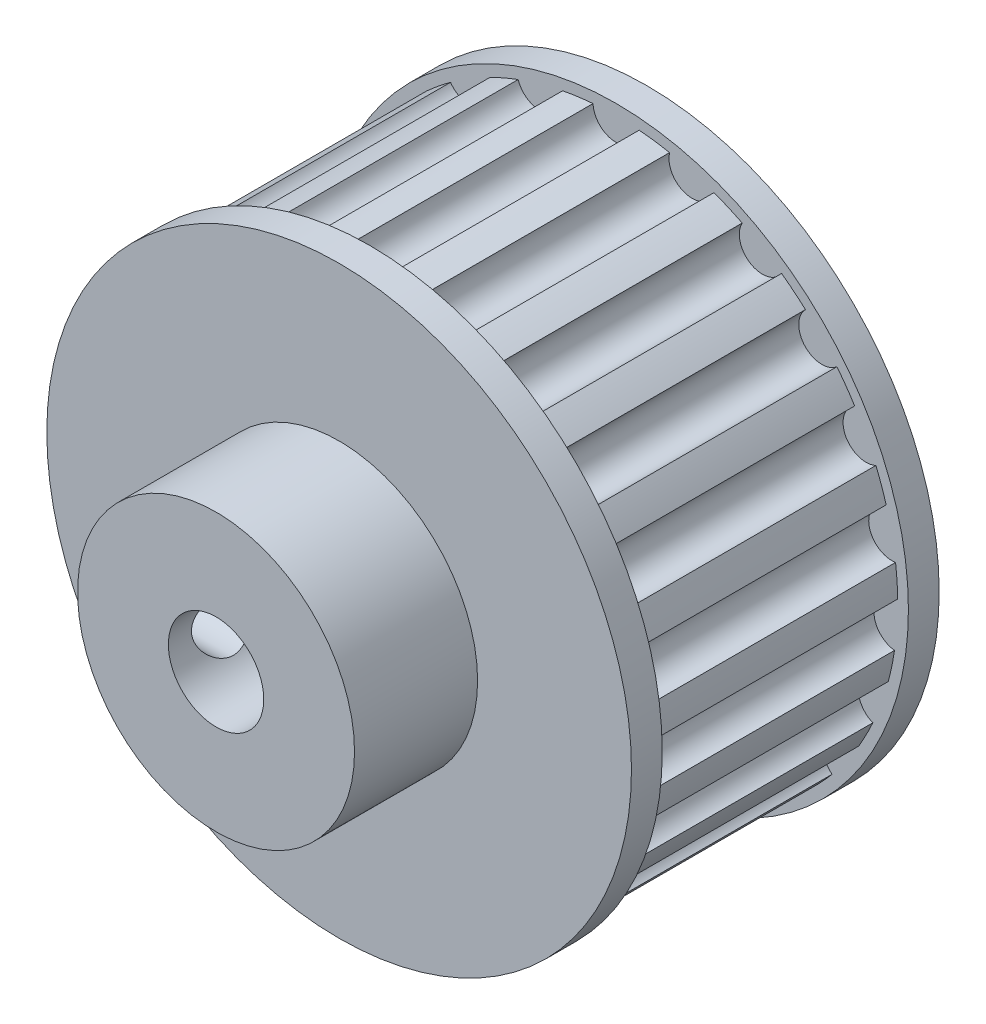
from build123d import *

# Parameters (mm, degrees)
EXTRUDE_1_DEPTH     = 16
SKETCH_2_R          = 19
EXTRUDE_2_DEPTH     = 2
SKETCH_3_R          = 19
EXTRUDE_3_DEPTH     = 2
SKETCH_4_R          = 9
SKETCH_4_R_2        = 3.1
EXTRUDE_4_DEPTH     = 8
SKETCH_5_R          = 2
CUT_EXTRUDE_1_DEPTH = 20


with BuildPart() as part:
    # Эскиз1 → Бобышка-Вытянуть1 (new body)
    with BuildSketch(Plane.XY):
        with BuildLine():
            ThreePointArc((-1.498740073, 18.241032987), (-2.492190095, 18.132029527), (-3.478209077, 17.968961235))
            ThreePointArc((-3.478209077, 17.968961235), (-4.533260247, 16.179417721), (-6.364534528, 17.16025077))
            ThreePointArc((-6.364534528, 17.16025077), (-7.291735947, 16.787259846), (-8.197195372, 16.364213831))
            ThreePointArc((-8.197195372, 16.364213831), (-8.73030932, 14.356382045), (-10.758300573, 14.806771256))
            ThreePointArc((-10.758300573, 14.806771256), (-11.550487101, 14.197455898), (-12.308233185, 13.545807547))
            ThreePointArc((-12.308233185, 13.545807547), (-12.27987129, 11.468599189), (-14.35417268, 11.355141255))
            ThreePointArc((-14.35417268, 11.355141255), (-14.952591467, 10.554691596), (-15.50642565, 9.722770687))
            ThreePointArc((-15.50642565, 9.722770687), (-14.918691382, 7.730242796), (-16.885461466, 7.061352373))
            ThreePointArc((-16.885461466, 7.061352373), (-17.245730527, 6.129134102), (-17.554577461, 5.178640403))
            ThreePointArc((-17.554577461, 5.178640403), (-16.451060383, 3.418569659), (-18.164432821, 2.243855289))
            ThreePointArc((-18.164432821, 2.243855289), (-18.259832648, 1.249006771), (-18.300786569, 0.250434051))
            ThreePointArc((-18.300786569, 0.250434051), (-16.763329494, -1.146643151), (-18.09623129, -2.740058277))
            ThreePointArc((-18.09623129, -2.740058277), (-17.919686515, -3.723753679), (-17.689710057, -4.696345849))
            ThreePointArc((-17.689710057, -4.696345849), (-15.832339144, -5.626814684), (-16.685915069, -7.520754256))
            ThreePointArc((-16.685915069, -7.520754256), (-16.25051921, -8.420340353), (-15.766668676, -9.294819262))
            ThreePointArc((-15.766668676, -9.294819262), (-13.727136627, -9.689671112), (-14.03808086, -11.743670296))
            ThreePointArc((-14.03808086, -11.743670296), (-13.376125236, -12.492428904), (-12.674285607, -13.203938451))
            ThreePointArc((-12.674285607, -13.203938451), (-10.603855185, -13.033888962), (-10.349106414, -15.095612034))
            ThreePointArc((-10.349106414, -15.095612034), (-9.509685246, -15.638011152), (-8.641908755, -16.133781929))
            ThreePointArc((-8.641908755, -16.133781929), (-6.694134312, -15.411442894), (-5.892586089, -17.327981286))
            ThreePointArc((-5.892586089, -17.327981286), (-4.937955404, -17.623793652), (-3.968601065, -17.867056608))
            ThreePointArc((-3.968601065, -17.867056608), (-2.287940121, -16.646000608), (-0.999039611, -18.275213435))
            ThreePointArc((-0.999039611, -18.275213435), (0, -18.3025), (0.999039611, -18.275213435))
            ThreePointArc((0.999039611, -18.275213435), (2.287940121, -16.646000608), (3.968601065, -17.867056608))
            ThreePointArc((3.968601065, -17.867056608), (4.937955404, -17.623793652), (5.892586089, -17.327981286))
            ThreePointArc((5.892586089, -17.327981286), (6.694134312, -15.411442894), (8.641908755, -16.133781929))
            ThreePointArc((8.641908755, -16.133781929), (9.509685246, -15.638011152), (10.349106414, -15.095612034))
            ThreePointArc((10.349106414, -15.095612034), (10.603855185, -13.033888962), (12.674285607, -13.203938451))
            ThreePointArc((12.674285607, -13.203938451), (13.376125236, -12.492428904), (14.03808086, -11.743670296))
            ThreePointArc((14.03808086, -11.743670296), (13.727136627, -9.689671112), (15.766668676, -9.294819262))
            ThreePointArc((15.766668676, -9.294819262), (16.25051921, -8.420340353), (16.685915069, -7.520754256))
            ThreePointArc((16.685915069, -7.520754256), (15.832339144, -5.626814684), (17.689710057, -4.696345849))
            ThreePointArc((17.689710057, -4.696345849), (17.919686515, -3.723753679), (18.09623129, -2.740058277))
            ThreePointArc((18.09623129, -2.740058277), (16.763329494, -1.146643151), (18.300786569, 0.250434051))
            ThreePointArc((18.300786569, 0.250434051), (18.259832648, 1.249006771), (18.164432821, 2.243855289))
            ThreePointArc((18.164432821, 2.243855289), (16.451060383, 3.418569659), (17.554577461, 5.178640403))
            ThreePointArc((17.554577461, 5.178640403), (17.245730527, 6.129134102), (16.885461466, 7.061352373))
            ThreePointArc((16.885461466, 7.061352373), (14.918691382, 7.730242796), (15.50642565, 9.722770687))
            ThreePointArc((15.50642565, 9.722770687), (14.952591467, 10.554691596), (14.35417268, 11.355141255))
            ThreePointArc((14.35417268, 11.355141255), (12.27987129, 11.468599189), (12.308233185, 13.545807547))
            ThreePointArc((12.308233185, 13.545807547), (11.550487101, 14.197455898), (10.758300573, 14.806771256))
            ThreePointArc((10.758300573, 14.806771256), (8.73030932, 14.356382045), (8.197195372, 16.364213831))
            ThreePointArc((8.197195372, 16.364213831), (7.291735947, 16.787259846), (6.364534528, 17.16025077))
            ThreePointArc((6.364534528, 17.16025077), (4.533260247, 16.179417721), (3.478209077, 17.968961235))
            ThreePointArc((3.478209077, 17.968961235), (2.492190095, 18.132029527), (1.498740073, 18.241032987))
            ThreePointArc((1.498740073, 18.241032987), (0, 16.8025), (-1.498740073, 18.241032987))
        make_face()
    extrude(amount=EXTRUDE_1_DEPTH)

    # Эскиз2 → Бобышка-Вытянуть2 (add)
    with BuildSketch(Plane(origin=(0, 0, 0), x_dir=(-1, 0, 0), z_dir=(0, 0, -1))):
        Circle(SKETCH_2_R)
    extrude(amount=EXTRUDE_2_DEPTH)

    # Эскиз3 → Бобышка-Вытянуть3 (add)
    with BuildSketch(Plane.XY.offset(16)):
        Circle(SKETCH_3_R)
    extrude(amount=EXTRUDE_3_DEPTH)

    # Эскиз4 → Бобышка-Вытянуть4 (add)
    with BuildSketch(Plane.XY.offset(18)):
        Circle(SKETCH_4_R)
        Circle(SKETCH_4_R_2, mode=Mode.SUBTRACT)
    extrude(amount=EXTRUDE_4_DEPTH)

    # Эскиз5 → Вырез-Вытянуть1 (cut, through all)
    with BuildSketch(Plane(origin=(0, 0, 0), x_dir=(0, 0, -1), z_dir=(1, 0, 0))):
        with Locations((-22.5, 0)):
            Circle(SKETCH_5_R)
    extrude(amount=-CUT_EXTRUDE_1_DEPTH, mode=Mode.SUBTRACT)


solid = part.part
